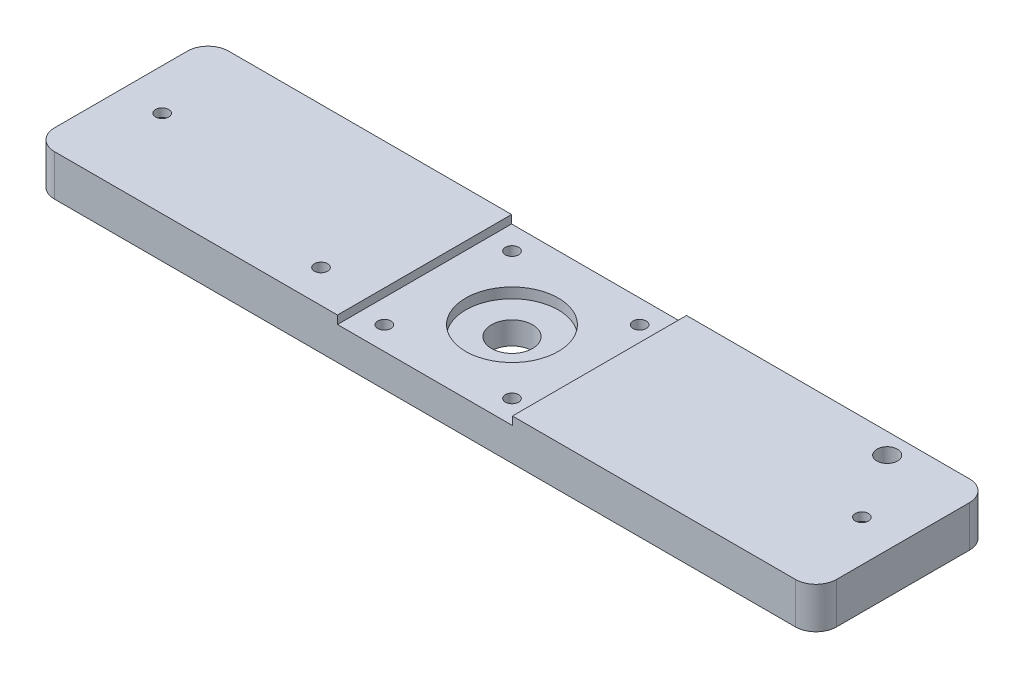
from build123d import *

# Parameters (mm, degrees)
SKETCH_1_W          = 190
SKETCH_1_H          = 42.3
EXTRUDE_1_DEPTH     = 10
SKETCH_2_W          = 42.5
SKETCH_2_H          = 49.677136544
CUT_EXTRUDE_1_DEPTH = 2
SKETCH_3_R          = 1.6
SKETCH_3_R_2        = 11.25
CUT_EXTRUDE_2_DEPTH = 2.5
SKETCH_4_R          = 5
CUT_EXTRUDE_3_DEPTH = 6.5
SKETCH_5_R          = 4.025
CUT_EXTRUDE_4_DEPTH = 8
SKETCH_6_R          = 1.6
CUT_EXTRUDE_5_DEPTH = 3
SKETCH_7_R          = 1.6
CUT_EXTRUDE_6_DEPTH = 3
FILLET_1_R          = 5
SKETCH_8_R          = 1.6
CUT_EXTRUDE_7_DEPTH = 9
CUT_EXTRUDE_8_REACH = 12
SKETCH_9_R          = 1.6
SKETCH_11_R         = 2.5
CUT_EXTRUDE_9_DEPTH = 11


with BuildPart() as part:
    # 草图1 → 凸台-拉伸1 (new body)
    with BuildSketch(Plane(origin=(0, 0, 0), x_dir=(1, 0, 0), z_dir=(0, 1, 0))):
        Rectangle(SKETCH_1_W, SKETCH_1_H)
    extrude(amount=EXTRUDE_1_DEPTH)

    # 草图2 → 切除-拉伸1 (cut)
    with BuildSketch(Plane(origin=(0, 10, 0), x_dir=(1, 0, 0), z_dir=(0, 1, 0))):
        Rectangle(SKETCH_2_W, SKETCH_2_H)
    extrude(amount=-CUT_EXTRUDE_1_DEPTH, mode=Mode.SUBTRACT)

    # 草图3 → 切除-拉伸2 (cut)
    with BuildSketch(Plane(origin=(0, 8, 0), x_dir=(1, 0, 0), z_dir=(0, 1, 0))):
        with Locations((-15.5, 15.5)):
            Circle(SKETCH_3_R)
        with Locations((15.5, 15.5)):
            Circle(SKETCH_3_R)
        with Locations((15.5, -15.5)):
            Circle(SKETCH_3_R)
        with Locations((-15.5, -15.5)):
            Circle(SKETCH_3_R)
        Circle(SKETCH_3_R_2)
    extrude(amount=-CUT_EXTRUDE_2_DEPTH, mode=Mode.SUBTRACT)

    # 草图4 → 切除-拉伸3 (cut, through all)
    with BuildSketch(Plane(origin=(0, 5.5, 0), x_dir=(1, 0, 0), z_dir=(0, 1, 0))):
        Circle(SKETCH_4_R)
    extrude(amount=-CUT_EXTRUDE_3_DEPTH, mode=Mode.SUBTRACT)

    # 草图5 → 切除-拉伸4 (cut)
    with BuildSketch(Plane.XZ):
        with Locations((-85, 0)):
            Circle(SKETCH_5_R)
        with Locations((85, 0)):
            Circle(SKETCH_5_R)
    extrude(amount=-CUT_EXTRUDE_4_DEPTH, mode=Mode.SUBTRACT)

    # 草图6 → 切除-拉伸5 (cut, through all)
    with BuildSketch(Plane.XZ.offset(-8)):
        with Locations((-85, 0)):
            Circle(SKETCH_6_R)
    extrude(amount=-CUT_EXTRUDE_5_DEPTH, mode=Mode.SUBTRACT)

    # 草图7 → 切除-拉伸6 (cut, through all)
    with BuildSketch(Plane.XZ.offset(-8)):
        with Locations((85, 0)):
            Circle(SKETCH_7_R)
    extrude(amount=-CUT_EXTRUDE_6_DEPTH, mode=Mode.SUBTRACT)

    # 圆角1
    fillet_1_edges = [part.edges().sort_by_distance(p)[0] for p in [
        (95, 5, 21.15),
        (-95, 5, 21.15),
        (-95, 5, -21.15),
        (95, 5, -21.15),
    ]]
    fillet(fillet_1_edges, radius=FILLET_1_R)

    # 草图8 → 切除-拉伸7 (cut, through all)
    with BuildSketch(Plane(origin=(0, 8, 0), x_dir=(1, 0, 0), z_dir=(0, 1, 0))):
        with Locations((15.5, 15.5)):
            Circle(SKETCH_8_R)
        with Locations((15.5, -15.5)):
            Circle(SKETCH_8_R)
        with Locations((-15.5, -15.5)):
            Circle(SKETCH_8_R)
        with Locations((-15.5, 15.5)):
            Circle(SKETCH_8_R)
    extrude(amount=-CUT_EXTRUDE_7_DEPTH, mode=Mode.SUBTRACT)

    # 草图9 → 切除-拉伸8 (cut, up to next)
    with BuildSketch(Plane(origin=(0, 10, 0), x_dir=(1, 0, 0), z_dir=(0, 1, 0)), mode=Mode.PRIVATE) as cut_extrude_8_sk1:
        with Locations((-33.25, -13.15)):
            Circle(SKETCH_9_R)
    cut_extrude_8_tool1 = extrude(cut_extrude_8_sk1.sketch, amount=-CUT_EXTRUDE_8_REACH, mode=Mode.PRIVATE) & part.part
    add(cut_extrude_8_tool1.solids().sort_by_distance((-33.25, 10, 13.15))[0], mode=Mode.SUBTRACT)

    # 草图11 → 切除-拉伸9 (cut, through all)
    with BuildSketch(Plane(origin=(0, 10, 0), x_dir=(1, 0, 0), z_dir=(0, 1, 0))):
        with Locations((75, 16.15)):
            Circle(SKETCH_11_R)
    extrude(amount=-CUT_EXTRUDE_9_DEPTH, mode=Mode.SUBTRACT)


solid = part.part
